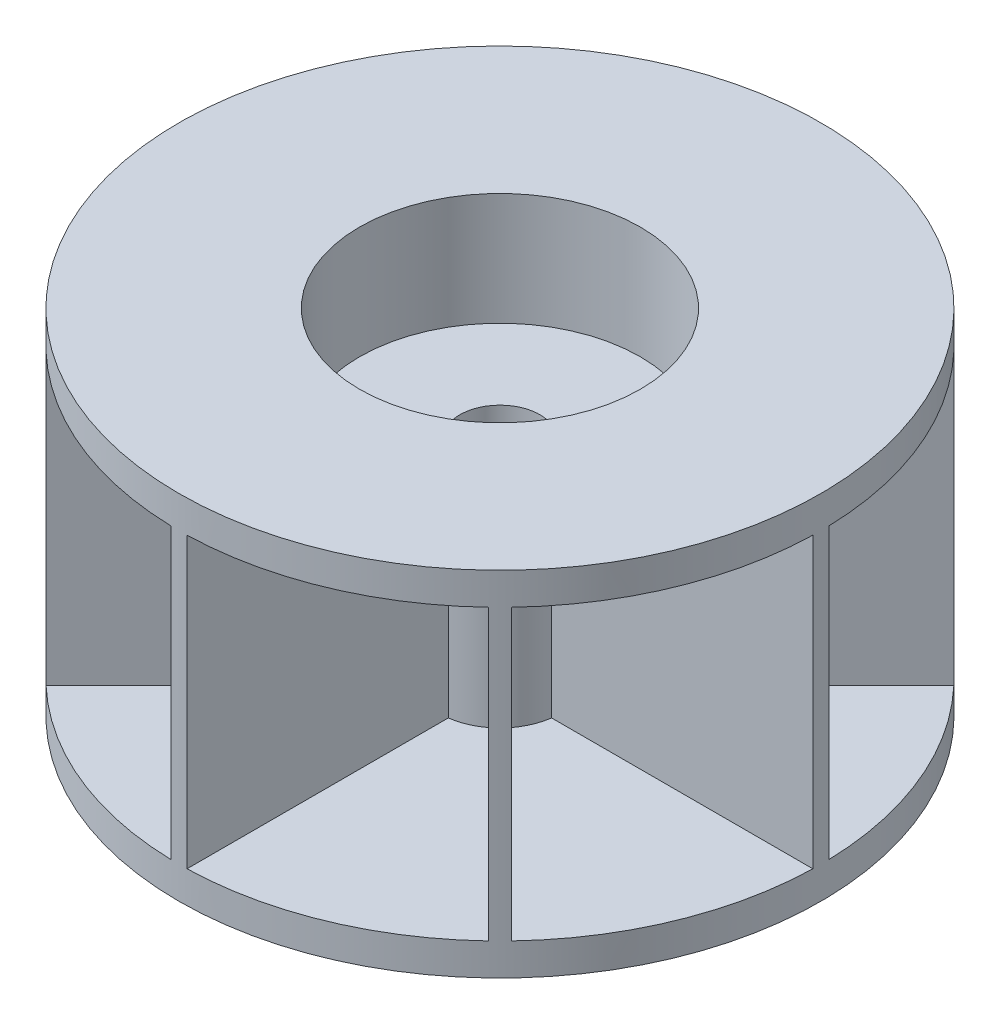
from build123d import *

# Parameters (mm, degrees)
SKETCH1_R           = 25.4
SKETCH1_R_2         = 3.175
BOSS_EXTRUDE1_DEPTH = 2.54
SKETCH2_R           = 3.175
BOSS_EXTRUDE4_DEPTH = 13.97
SKETCH5_R           = 11.1125
SKETCH5_R_2         = 3.175
BOSS_EXTRUDE6_DEPTH = 2.54
SKETCH5_4_R         = 11.1125
BOSS_EXTRUDE7_DEPTH = 8.89
SKETCH6_R           = 25.4
SKETCH6_R_2         = 11.1125
BOSS_EXTRUDE8_DEPTH = 2.54


with BuildPart() as part:
    # Sketch1 → Boss-Extrude1 (new body)
    with BuildSketch(Plane(origin=(0, 0, 0), x_dir=(1, 0, 0), z_dir=(0, 1, 0))):
        Circle(SKETCH1_R)
        Circle(SKETCH1_R_2, mode=Mode.SUBTRACT)
    extrude(amount=BOSS_EXTRUDE1_DEPTH)

    # Sketch2 → Boss-Extrude4 (add)
    with BuildSketch(Plane(origin=(0, 2.54, 0), x_dir=(1, 0, 0), z_dir=(0, 1, 0))):
        with BuildLine():
            ThreePointArc((0.635, 25.392061259), (0, 25.4), (-0.635, 25.392061259))
            Line((-0.635, 25.392061259), (-0.635, 4.719976827))
            ThreePointArc((-0.635, 4.719976827), (-1.822529847, 4.399976274), (-2.888514816, 3.786540428))
            Line((-2.888514816, 3.786540428), (-17.505885899, 18.403911511))
            ThreePointArc((-17.505885899, 18.403911511), (-17.960512242, 17.960512242), (-18.403911511, 17.505885899))
            Line((-18.403911511, 17.505885899), (-3.786540428, 2.888514816))
            ThreePointArc((-3.786540428, 2.888514816), (-4.399976274, 1.822529847), (-4.719976827, 0.635))
            Line((-4.719976827, 0.635), (-25.392061259, 0.635))
            ThreePointArc((-25.392061259, 0.635), (-25.4, 0), (-25.392061259, -0.635))
            Line((-25.392061259, -0.635), (-4.719976827, -0.635))
            ThreePointArc((-4.719976827, -0.635), (-4.399976274, -1.822529847), (-3.786540428, -2.888514816))
            Line((-3.786540428, -2.888514816), (-18.403911511, -17.505885899))
            ThreePointArc((-18.403911511, -17.505885899), (-17.960512242, -17.960512242), (-17.505885899, -18.403911511))
            Line((-17.505885899, -18.403911511), (-2.888514816, -3.786540428))
            ThreePointArc((-2.888514816, -3.786540428), (-1.822529847, -4.399976274), (-0.635, -4.719976827))
            Line((-0.635, -4.719976827), (-0.635, -25.392061259))
            ThreePointArc((-0.635, -25.392061259), (0, -25.4), (0.635, -25.392061259))
            Line((0.635, -25.392061259), (0.635, -4.719976827))
            ThreePointArc((0.635, -4.719976827), (1.822529847, -4.399976274), (2.888514816, -3.786540428))
            Line((2.888514816, -3.786540428), (17.505885899, -18.403911511))
            ThreePointArc((17.505885899, -18.403911511), (17.960512242, -17.960512242), (18.403911511, -17.505885899))
            Line((18.403911511, -17.505885899), (3.786540428, -2.888514816))
            ThreePointArc((3.786540428, -2.888514816), (4.399976274, -1.822529847), (4.719976827, -0.635))
            Line((4.719976827, -0.635), (25.392061259, -0.635))
            ThreePointArc((25.392061259, -0.635), (25.4, 0), (25.392061259, 0.635))
            Line((25.392061259, 0.635), (4.719976827, 0.635))
            ThreePointArc((4.719976827, 0.635), (4.399976274, 1.822529847), (3.786540428, 2.888514816))
            Line((3.786540428, 2.888514816), (18.403911511, 17.505885899))
            ThreePointArc((18.403911511, 17.505885899), (17.960512242, 17.960512242), (17.505885899, 18.403911511))
            Line((17.505885899, 18.403911511), (2.888514816, 3.786540428))
            ThreePointArc((2.888514816, 3.786540428), (1.822529847, 4.399976274), (0.635, 4.719976827))
            Line((0.635, 4.719976827), (0.635, 25.392061259))
        make_face()
        Circle(SKETCH2_R, mode=Mode.SUBTRACT)
    extrude(amount=BOSS_EXTRUDE4_DEPTH)

    # Sketch5 → Boss-Extrude6 (add)
    with BuildSketch(Plane(origin=(0, 16.51, 0), x_dir=(1, 0, 0), z_dir=(0, 1, 0))):
        Circle(SKETCH5_R)
        Circle(SKETCH5_R_2, mode=Mode.SUBTRACT)
    extrude(amount=BOSS_EXTRUDE6_DEPTH)

    # Sketch5_4 → Boss-Extrude7 (add)
    with BuildSketch(Plane(origin=(0, 16.51, 0), x_dir=(1, 0, 0), z_dir=(0, 1, 0))):
        with BuildLine():
            ThreePointArc((0.635, -12.684115066), (4.860079591, -11.733270063), (8.52001097, -9.418036582))
            Line((8.52001097, -9.418036582), (17.505885899, -18.403911511))
            ThreePointArc((17.505885899, -18.403911511), (17.960512242, -17.960512242), (18.403911511, -17.505885899))
            Line((18.403911511, -17.505885899), (9.418036582, -8.52001097))
            ThreePointArc((9.418036582, -8.52001097), (11.733270063, -4.860079591), (12.684115066, -0.635))
            Line((12.684115066, -0.635), (25.392061259, -0.635))
            ThreePointArc((25.392061259, -0.635), (25.4, 0), (25.392061259, 0.635))
            Line((25.392061259, 0.635), (12.684115066, 0.635))
            ThreePointArc((12.684115066, 0.635), (11.733270063, 4.860079591), (9.418036582, 8.52001097))
            Line((9.418036582, 8.52001097), (18.403911511, 17.505885899))
            ThreePointArc((18.403911511, 17.505885899), (17.960512242, 17.960512242), (17.505885899, 18.403911511))
            Line((17.505885899, 18.403911511), (8.52001097, 9.418036582))
            ThreePointArc((8.52001097, 9.418036582), (4.860079591, 11.733270063), (0.635, 12.684115066))
            Line((0.635, 12.684115066), (0.635, 25.392061259))
            ThreePointArc((0.635, 25.392061259), (0, 25.4), (-0.635, 25.392061259))
            Line((-0.635, 25.392061259), (-0.635, 12.684115066))
            ThreePointArc((-0.635, 12.684115066), (-4.860079591, 11.733270063), (-8.52001097, 9.418036582))
            Line((-8.52001097, 9.418036582), (-17.505885899, 18.403911511))
            ThreePointArc((-17.505885899, 18.403911511), (-17.960512242, 17.960512242), (-18.403911511, 17.505885899))
            Line((-18.403911511, 17.505885899), (-9.418036582, 8.52001097))
            ThreePointArc((-9.418036582, 8.52001097), (-11.733270063, 4.860079591), (-12.684115066, 0.635))
            Line((-12.684115066, 0.635), (-25.392061259, 0.635))
            ThreePointArc((-25.392061259, 0.635), (-25.4, 0), (-25.392061259, -0.635))
            Line((-25.392061259, -0.635), (-12.684115066, -0.635))
            ThreePointArc((-12.684115066, -0.635), (-11.733270063, -4.860079591), (-9.418036582, -8.52001097))
            Line((-9.418036582, -8.52001097), (-18.403911511, -17.505885899))
            ThreePointArc((-18.403911511, -17.505885899), (-17.960512242, -17.960512242), (-17.505885899, -18.403911511))
            Line((-17.505885899, -18.403911511), (-8.52001097, -9.418036582))
            ThreePointArc((-8.52001097, -9.418036582), (-4.860079591, -11.733270063), (-0.635, -12.684115066))
            Line((-0.635, -12.684115066), (-0.635, -25.392061259))
            ThreePointArc((-0.635, -25.392061259), (0, -25.4), (0.635, -25.392061259))
            Line((0.635, -25.392061259), (0.635, -12.684115066))
        make_face()
        Circle(SKETCH5_4_R, mode=Mode.SUBTRACT)
    extrude(amount=BOSS_EXTRUDE7_DEPTH)

    # Sketch6 → Boss-Extrude8 (add)
    with BuildSketch(Plane(origin=(0, 25.4, 0), x_dir=(1, 0, 0), z_dir=(0, 1, 0))):
        Circle(SKETCH6_R)
        Circle(SKETCH6_R_2, mode=Mode.SUBTRACT)
    extrude(amount=BOSS_EXTRUDE8_DEPTH)


solid = part.part
